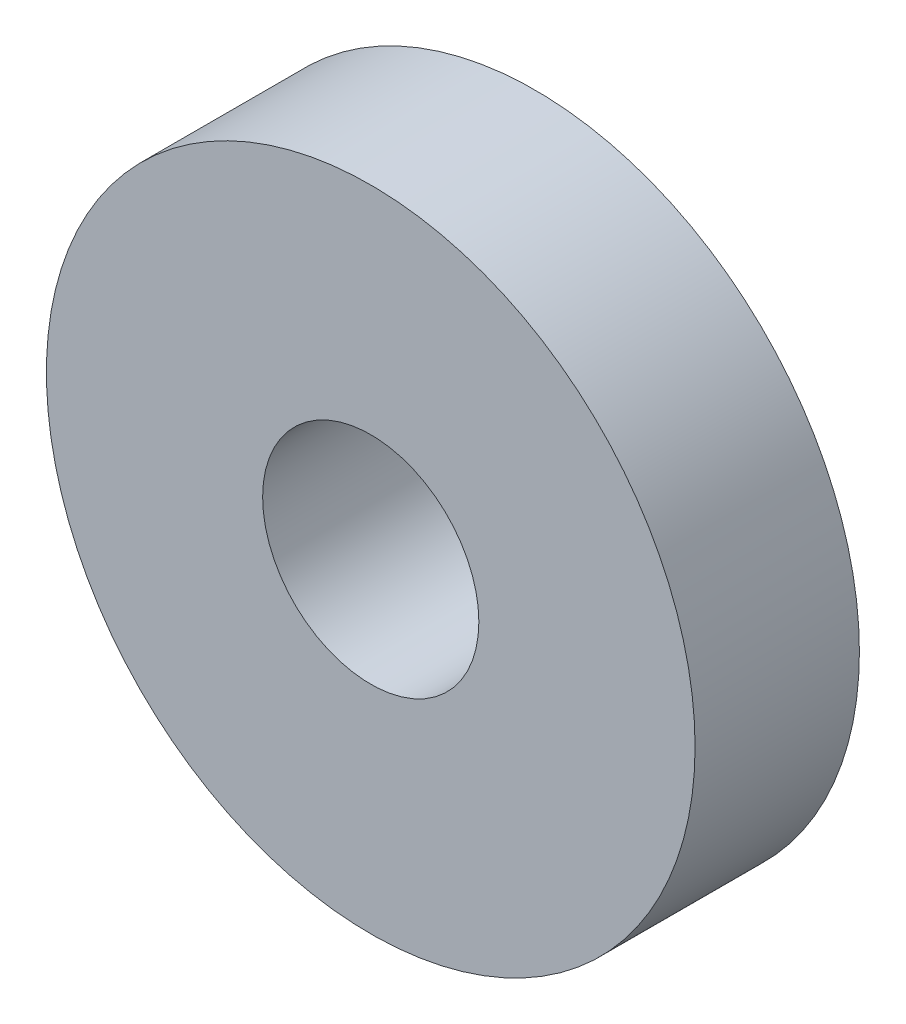
from build123d import *

# Parameters (mm, degrees)
SKETCH_1_R      = 7.5
SKETCH_1_R_2    = 2.5001
EXTRUDE_1_DEPTH = 3.8


with BuildPart() as part:
    # Эскиз1 → Бобышка-Вытянуть1 (new body)
    with BuildSketch(Plane.XY):
        Circle(SKETCH_1_R)
        Circle(SKETCH_1_R_2, mode=Mode.SUBTRACT)
    extrude(amount=-EXTRUDE_1_DEPTH)


solid = part.part
